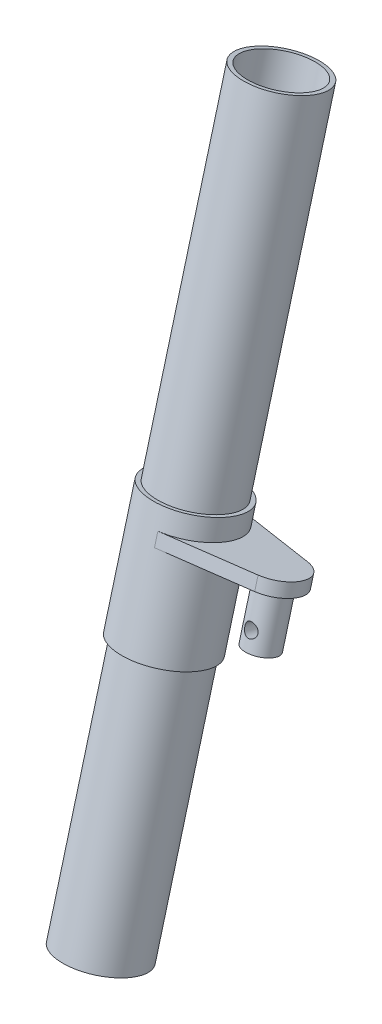
from build123d import *

# Parameters (mm, degrees)
BOSS_EXTRUDE1_DEPTH     = 3.75
SKETCH5_R               = 9
BOSS_EXTRUDE2_DEPTH     = 30
SHELL1_T                = -2.5
SKETCH6_R               = 3.75
CUT_EXTRUDE2_DEPTH      = 332.181551676
CUT_EXTRUDE2_DEPTH_BACK = 332.181551676


with BuildPart() as part:
    # Sketch2 → Revolve1 (revolve)
    with BuildSketch(Plane(origin=(0, 0, 0), x_dir=(0, 0, -1), z_dir=(1, 0, 0))):
        Polygon((37.030704723, 80.244921888), (-66.496913318, -306.125408627), (-88.23024441, -300.301980112), (15.297373631, 86.068350403), align=None)
    revolve(axis=Axis((0, -300.301980112, 88.23024441), (0, 0.9659258262890701, -0.25881904510251424)))

    # Shell1
    shell1_openings = [part.faces().sort_by_distance(p)[0] for p in [
        (0, -300.301980112, 88.23024441),
        (0, 86.068350403, -15.297373631),
    ]]
    offset(amount=SHELL1_T, openings=shell1_openings, kind=Kind.INTERSECTION)


with BuildPart() as body_2:
    # Sketch3 → Revolve2 (revolve)
    with BuildSketch(Plane(origin=(0, 0, 0), x_dir=(0, 0, -1), z_dir=(1, 0, 0))):
        Polygon((-12.144913847, -103.280985107), (-30.262247004, -170.895792947), (-27.847432438, -171.54284056), (-9.730099281, -103.928032719), align=None)
    revolve(axis=Axis((0, -300.301980112, 88.23024441), (0, 0.9659258262890701, -0.25881904510251424)))


with BuildPart() as body_3:
    # Sketch4 → Boss-Extrude1 (new, symmetric)
    with BuildSketch(Plane(origin=(0, -114.02695461, 30.553430403), x_dir=(1, 0, 0), z_dir=(0, 0.96592582628907, -0.25881904510251447))):
        with BuildLine():
            Line((53, 7.196938457), (5, 16.994897428))
            ThreePointArc((5, 16.994897428), (25, -7.5), (5, -31.994897428))
            Line((5, -31.994897428), (53, -22.196938457))
            ThreePointArc((53, -22.196938457), (65, -7.5), (53, 7.196938457))
        make_face()
    extrude(amount=BOSS_EXTRUDE1_DEPTH, both=True)


with BuildPart() as body_4:
    # Sketch5 → Boss-Extrude2 (new body)
    with BuildSketch(Plane(origin=(0, -117.649176458, 31.524001822), x_dir=(1, 0, 0), z_dir=(0, -0.96592582628907, 0.25881904510251447))):
        with Locations(Location((50, 7.5, 0), (0, 0, 270))):
            Circle(SKETCH5_R)
    extrude(amount=BOSS_EXTRUDE2_DEPTH)

    # Sketch6 → Cut-Extrude2 (cut, two sides)
    with BuildSketch(Plane(origin=(0, 1.941142838, 7.244443697), x_dir=(1, 0, 0), z_dir=(0, 0.2588190451025143, 0.9659258262890701))) as cut_extrude2_sk:
        with Locations(Location((50, -141.799390032, 0), (0, 0, 270))):
            Circle(SKETCH6_R)
    extrude(amount=CUT_EXTRUDE2_DEPTH, mode=Mode.SUBTRACT)
    extrude(cut_extrude2_sk.sketch, amount=-CUT_EXTRUDE2_DEPTH_BACK, mode=Mode.SUBTRACT)


solid = Compound([part.part, body_2.part, body_3.part, body_4.part])
